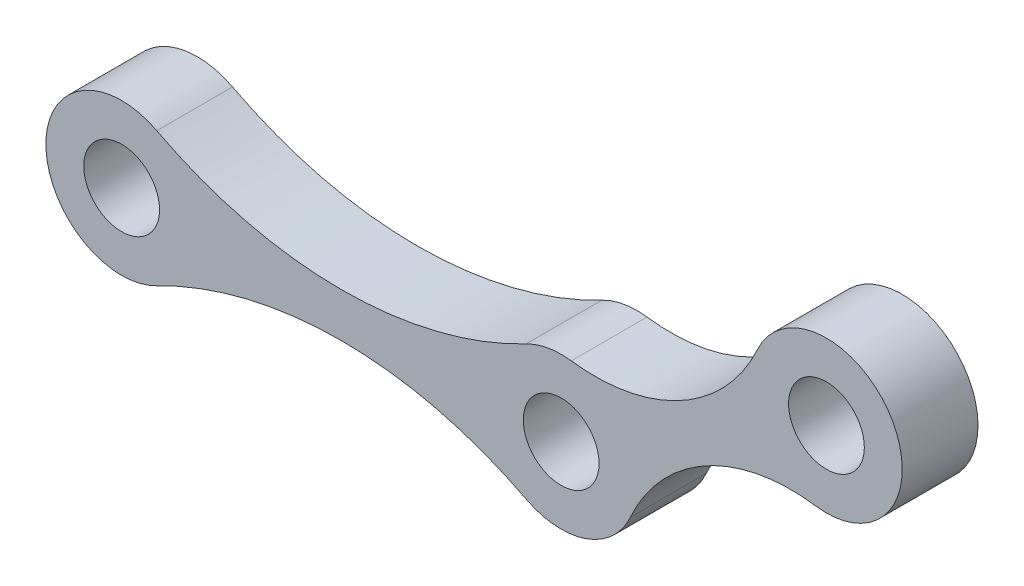
from build123d import *

# Parameters (mm, degrees)
SKETCH_1_R          = 2.5
EXTRUDE_1_DEPTH     = 2.5
SKETCH_2_OUTSIDE_W  = 70.512
SKETCH_2_OUTSIDE_H  = 33.683
CUT_EXTRUDE_1_DEPTH = 5


with BuildPart() as part:
    # 草圖1 → 填料-伸長1 (new body, symmetric)
    with BuildSketch(Plane.XY):
        with BuildLine():
            Line((45.485924683, 14.569854348), (-1.018385662, 4.895190563))
            ThreePointArc((-1.018385662, 4.895190563), (-4.973728622, -0.511882402), (0, -5))
            Line((0, -5), (29, -5))
            ThreePointArc((29, -5), (30.248921949, -4.841507406), (31.418665946, -4.376077586))
            Line((31.418665946, -4.376077586), (48.922976291, 5.298586199))
            ThreePointArc((48.922976291, 5.298586199), (51.192518904, 11.412680042), (45.485924683, 14.569854348))
        make_face()
        with Locations((46.504310345, 9.674663785)):
            Circle(SKETCH_1_R, mode=Mode.SUBTRACT)
        with Locations((29, 0)):
            Circle(SKETCH_1_R, mode=Mode.SUBTRACT)
        Circle(SKETCH_1_R, mode=Mode.SUBTRACT)
    extrude(amount=EXTRUDE_1_DEPTH, both=True)

    # 草圖2 outside → 除料-伸長1 (cut)
    with BuildSketch(Plane.XY.offset(2.5)):
        with Locations((23.252, 4.8375)):
            Rectangle(SKETCH_2_OUTSIDE_W, SKETCH_2_OUTSIDE_H)
        with BuildLine():
            ThreePointArc((45.79340971, 4.725459779), (50.890857954, 12.074288771), (41.953237231, 11.745348096))
            ThreePointArc((41.953237231, 11.745348096), (36.933542301, 6.318443182), (29.667856416, 4.955196041))
            ThreePointArc((29.667856416, 4.955196041), (28.134691665, 4.924554953), (26.682918959, 4.43070372))
            ThreePointArc((26.682918959, 4.43070372), (14.5, 1.437415904), (2.317081041, 4.43070372))
            ThreePointArc((2.317081041, 4.43070372), (-4.999984203, 0.012568795), (2.294776385, -4.442296855))
            ThreePointArc((2.294776385, -4.442296855), (14.5, -1.476041996), (26.705223615, -4.442296855))
            ThreePointArc((26.705223615, -4.442296855), (30.657237876, -4.717368188), (33.568899121, -2.031049192))
            ThreePointArc((33.568899121, -2.031049192), (38.547411457, 3.398479533), (45.79340971, 4.725459779))
        make_face(mode=Mode.SUBTRACT)
    extrude(amount=-CUT_EXTRUDE_1_DEPTH, mode=Mode.SUBTRACT)


solid = part.part
